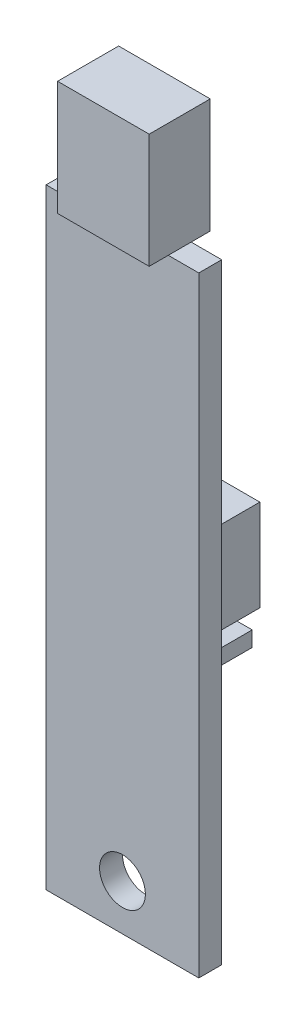
from build123d import *

# Parameters (mm, degrees)
SKETCH_2_W      = 10
SKETCH_2_H      = 40
SKETCH_2_R      = 1.5
EXTRUDE_1_DEPTH = 1.5
SKETCH_3_3_W    = 6
SKETCH_3_3_H    = 6
EXTRUDE_3_DEPTH = 6
SKETCH_3_4_W    = 6
SKETCH_3_4_H    = 2
EXTRUDE_4_DEPTH = 2
SKETCH_4_W      = 1
SKETCH_4_H      = 1
EXTRUDE_5_DEPTH = 4
SKETCH_6_W      = 6
SKETCH_6_H      = 4
EXTRUDE_6_DEPTH = 7.5


with BuildPart() as part:
    # 草圖2 → 填料-伸長1 (new body)
    with BuildSketch(Plane.XY):
        with Locations((5, 20)):
            Rectangle(SKETCH_2_W, SKETCH_2_H)
        with Locations((5, 3)):
            Circle(SKETCH_2_R, mode=Mode.SUBTRACT)
    extrude(amount=EXTRUDE_1_DEPTH)

    # 草圖3<3> → 填料-伸長3 (add)
    with BuildSketch(Plane.XY.offset(1.5)):
        with Locations((5, 20)):
            Rectangle(SKETCH_3_3_W, SKETCH_3_3_H)
    extrude(amount=-EXTRUDE_3_DEPTH)

    # 草圖3<4> → 填料-伸長4 (add)
    with BuildSketch(Plane.XY.offset(1.5)):
        with Locations((5, 15)):
            Rectangle(SKETCH_3_4_W, SKETCH_3_4_H)
    extrude(amount=-EXTRUDE_4_DEPTH)

    # 草圖4 → 填料-伸長5 (add)
    with BuildSketch(Plane(origin=(0, 0, -0.5), x_dir=(-1, 0, 0), z_dir=(0, 0, -1))):
        with Locations((-5, 15)):
            Rectangle(SKETCH_4_W, SKETCH_4_H)
        with Locations((-7, 15)):
            Rectangle(SKETCH_4_W, SKETCH_4_H)
        with Locations((-3, 15)):
            Rectangle(SKETCH_4_W, SKETCH_4_H)
    extrude(amount=EXTRUDE_5_DEPTH)

    # 草圖6 → 填料-伸長6 (add)
    with BuildSketch(Plane(origin=(0, 40, 0), x_dir=(1, 0, 0), z_dir=(0, 1, 0))):
        with Locations((5, -0.75)):
            Rectangle(SKETCH_6_W, SKETCH_6_H)
    extrude(amount=EXTRUDE_6_DEPTH)


solid = part.part
